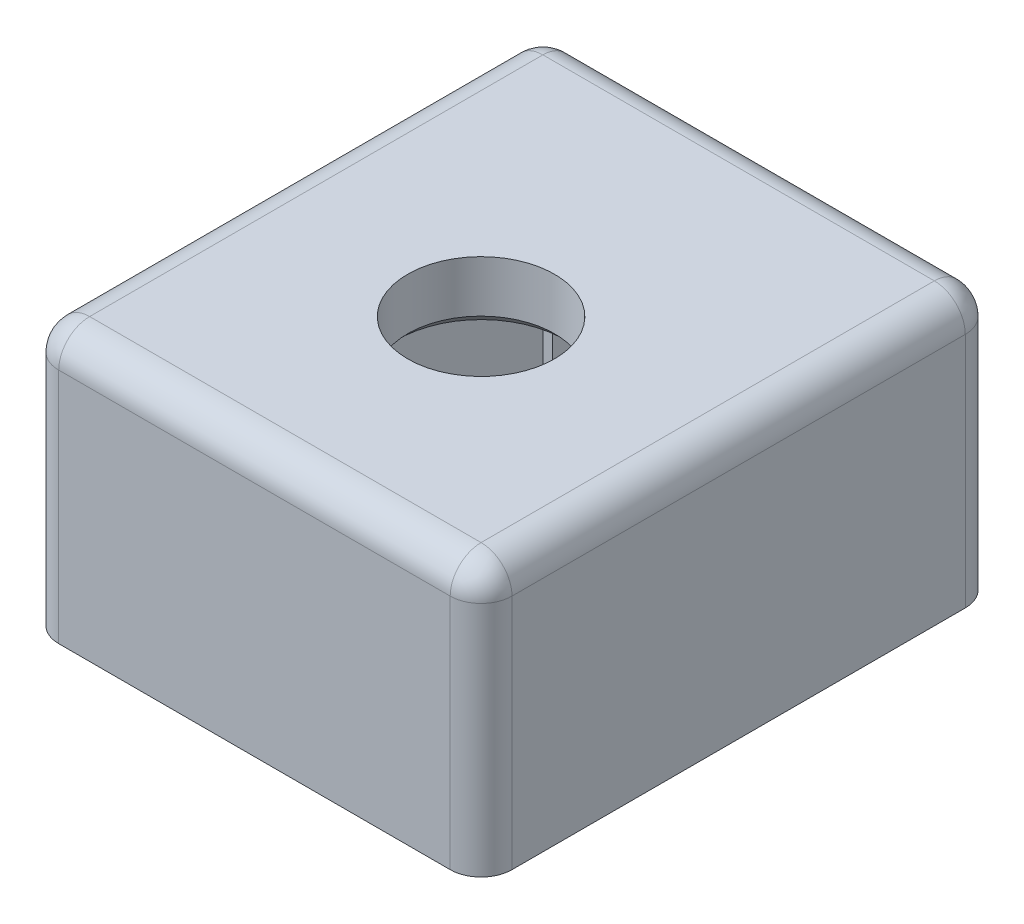
from build123d import *

# Parameters (mm, degrees)
SKETCH1_W           = 22
SKETCH1_H           = 25
SKETCH1_R           = 3.5625
BOSS_EXTRUDE1_DEPTH = 3
CUT_EXTRUDE1_DEPTH  = 2
SKETCH2_W           = 22
SKETCH2_H           = 25
SKETCH2_W_2         = 18
SKETCH2_H_2         = 21
BOSS_EXTRUDE2_DEPTH = 10
FILLET1_R           = 1.5
CHAMFER2_SIZE       = 0.5
FILLET2_R           = 0.5
SKETCH6_W           = 17.056767778
SKETCH6_H           = 17.056767778
CUT_EXTRUDE4_DEPTH  = 3


with BuildPart() as part:
    # Sketch1 → Boss-Extrude1 (new body)
    with BuildSketch(Plane(origin=(0, 0, 0), x_dir=(1, 0, 0), z_dir=(0, 1, 0))):
        with Locations((0, 1.5)):
            Rectangle(SKETCH1_W, SKETCH1_H)
        with Locations(Location((0, 0, 0), (0, 0, 270))):
            Circle(SKETCH1_R, mode=Mode.SUBTRACT)
    extrude(amount=BOSS_EXTRUDE1_DEPTH)

    # 3DSketch1 → Cut-Extrude1 (cut)
    with BuildSketch(Plane(origin=(8.5, 0, -1.375), x_dir=(-0.5881716976750463, 0, 0.8087360843031886), z_dir=(0, -1, 0))):
        Polygon((0, 0), (1.176343395, 1.617472169), (3.400367627, 0), (2.224024232, -1.617472169), align=None)
    extrude(amount=-CUT_EXTRUDE1_DEPTH, mode=Mode.SUBTRACT)

    # Sketch2 → Boss-Extrude2 (add)
    with BuildSketch(Plane.XZ):
        with Locations((0, -1.5)):
            Rectangle(SKETCH2_W, SKETCH2_H)
        with Locations((0, -1.5)):
            Rectangle(SKETCH2_W_2, SKETCH2_H_2, mode=Mode.SUBTRACT)
    extrude(amount=BOSS_EXTRUDE2_DEPTH)

    # Fillet1
    fillet1_edges = [part.edges().sort_by_distance(p)[0] for p in [
        (11, 3, -1.5),
        (0, 3, -14),
        (-11, 3, -1.5),
        (0, 3, 11),
        (-11, -3.5, -14),
        (11, -3.5, -14),
        (11, -3.5, 11),
        (-11, -3.5, 11),
    ]]
    fillet(fillet1_edges, radius=FILLET1_R)

    # Chamfer2
    chamfer2_edges = [part.edges().sort_by_distance(p)[0] for p in [
        (0, 0, -3.5625),
    ]]
    chamfer(chamfer2_edges, length=CHAMFER2_SIZE)

    # Fillet2
    fillet2_edges = [part.edges().sort_by_distance(p)[0] for p in [
        (8.5, 1, -1.375),
        (8.5, 1, 1.375),
        (6.5, 1, 1.375),
        (6.5, 1, -1.375),
    ]]
    fillet(fillet2_edges, radius=FILLET2_R)

    # Sketch6 → Cut-Extrude4 (cut)
    with BuildSketch(Plane(origin=(0, 0, -14), x_dir=(-1, 0, 0), z_dir=(0, 0, -1))):
        with Locations((0, -10)):
            Rectangle(SKETCH6_W, SKETCH6_H)
    extrude(amount=-CUT_EXTRUDE4_DEPTH, mode=Mode.SUBTRACT)


solid = part.part
